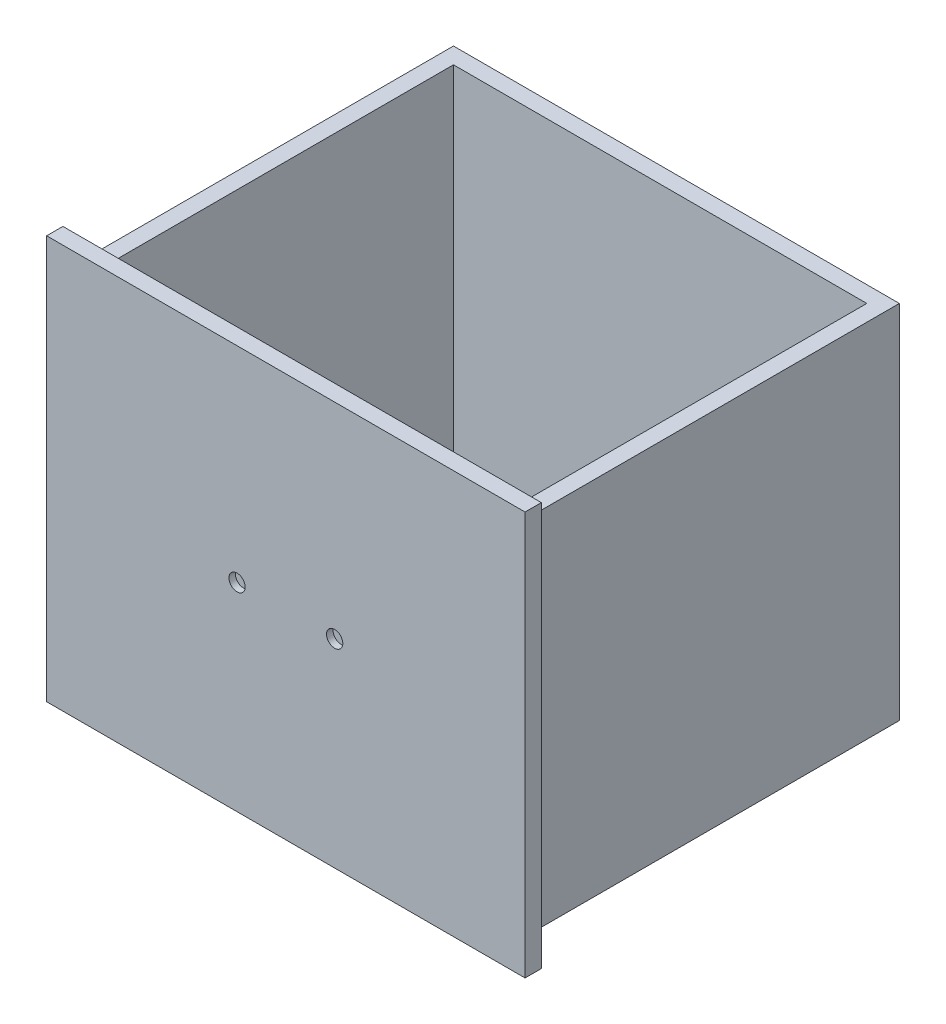
from build123d import *

# Parameters (mm, degrees)
SKETCH1_W           = 373.38
SKETCH1_H           = 309.88
BOSS_EXTRUDE1_DEPTH = 12.7
SKETCH2_W           = 347.98
SKETCH2_H           = 281.94
BOSS_EXTRUDE2_DEPTH = 292.1
SKETCH3_W           = 322.58
SKETCH3_H           = 279.4
CUT_EXTRUDE1_DEPTH  = 266.7
SKETCH4_R           = 6.35
CUT_EXTRUDE2_DEPTH  = 5.08
SKETCH5_W           = 373.38
SKETCH5_H           = 5.08
BOSS_EXTRUDE3_DEPTH = 12.7


with BuildPart() as part:
    # Sketch1 → Boss-Extrude1 (new body)
    with BuildSketch(Plane.XY):
        Rectangle(SKETCH1_W, SKETCH1_H)
    extrude(amount=-BOSS_EXTRUDE1_DEPTH)

    # Sketch2 → Boss-Extrude2 (add)
    with BuildSketch(Plane(origin=(0, 0, -12.7), x_dir=(-1, 0, 0), z_dir=(0, 0, -1))):
        with Locations((0, 1.27)):
            Rectangle(SKETCH2_W, SKETCH2_H)
    extrude(amount=BOSS_EXTRUDE2_DEPTH)

    # Sketch3 → Cut-Extrude1 (cut)
    with BuildSketch(Plane(origin=(0, 142.24, 0), x_dir=(1, 0, 0), z_dir=(0, 1, 0))):
        with Locations((0, 152.4)):
            Rectangle(SKETCH3_W, SKETCH3_H)
    extrude(amount=-CUT_EXTRUDE1_DEPTH, mode=Mode.SUBTRACT)

    # Sketch4 → Cut-Extrude2 (cut)
    with BuildSketch(Plane.XY):
        with Locations((-38.1, 0)):
            Circle(SKETCH4_R)
        with Locations((38.1, 0)):
            Circle(SKETCH4_R)
    extrude(amount=-CUT_EXTRUDE2_DEPTH, mode=Mode.SUBTRACT)

    # Sketch5 → Boss-Extrude3 (add)
    with BuildSketch(Plane.XY):
        with Locations((0, 157.48)):
            Rectangle(SKETCH5_W, SKETCH5_H)
    extrude(amount=-BOSS_EXTRUDE3_DEPTH)


solid = part.part
